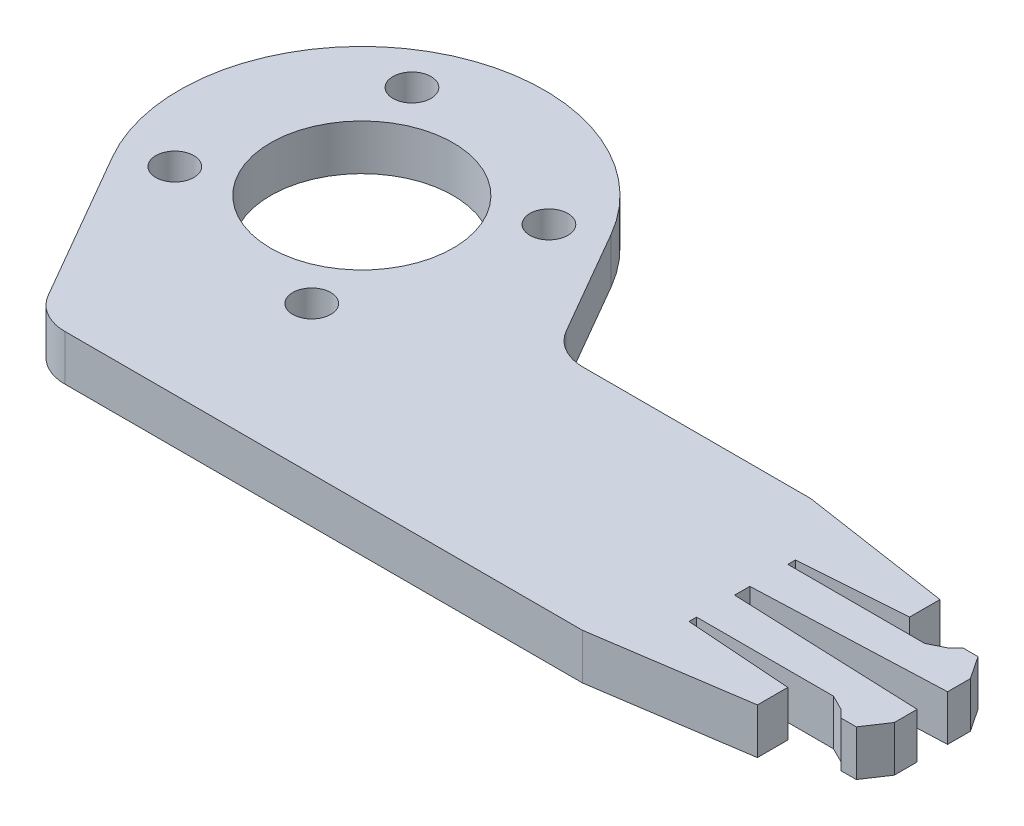
from build123d import *

# Parameters (mm, degrees)
SKETCH1_R           = 1.25
SKETCH1_R_2         = 6
BOSS_EXTRUDE1_DEPTH = 1.5
FILLET1_R           = 3


with BuildPart() as part:
    # Sketch1 → Boss-Extrude1 (new body, symmetric)
    with BuildSketch(Plane(origin=(0, 0, 0), x_dir=(1, 0, 0), z_dir=(0, 1, 0))):
        with BuildLine():
            Line((42, -16), (32, -17.5))
            Line((32, -17.5), (-3.75277675, -17.5))
            Line((-3.75277675, -17.5), (-10.392304845, -6))
            ThreePointArc((-10.392304845, -6), (-6, 10.392304845), (10.392304845, 6))
            Line((10.392304845, 6), (15.299782134, -2.5))
            Line((15.299782134, -2.5), (32, -2.5))
            Line((32, -2.5), (42, -4))
            Line((42, -4), (42, -6))
            Line((42, -6), (35, -6.5))
            Line((35, -6.5), (35, -7))
            Line((35, -7), (44, -7))
            Line((44, -7), (45, -6.5))
            Line((45, -6.5), (45.5, -6))
            Line((45.5, -6), (46.5, -6))
            Line((46.5, -6), (47.5, -7.5))
            Line((47.5, -7.5), (47.5, -9))
            Line((47.5, -9), (35, -9.5))
            Line((35, -9.5), (35, -10.5))
            Line((35, -10.5), (47.5, -11))
            Line((47.5, -11), (47.5, -12.5))
            Line((47.5, -12.5), (46.5, -14))
            Line((46.5, -14), (45.5, -14))
            Line((45.5, -14), (45, -13.5))
            Line((45, -13.5), (44, -13))
            Line((44, -13), (35, -13))
            Line((35, -13), (35, -13.5))
            Line((35, -13.5), (42, -14))
            Line((42, -14), (42, -16))
        make_face()
        with Locations((4.5, -7.794228634)):
            Circle(SKETCH1_R, mode=Mode.SUBTRACT)
        with Locations((-7.794228634, -4.5)):
            Circle(SKETCH1_R, mode=Mode.SUBTRACT)
        with Locations((-4.5, 7.794228634)):
            Circle(SKETCH1_R, mode=Mode.SUBTRACT)
        with Locations((7.794228634, 4.5)):
            Circle(SKETCH1_R, mode=Mode.SUBTRACT)
        Circle(SKETCH1_R_2, mode=Mode.SUBTRACT)
    extrude(amount=BOSS_EXTRUDE1_DEPTH, both=True)

    # Fillet1
    fillet1_edges = [part.edges().sort_by_distance(p)[0] for p in [
        (-3.75277675, 0, 17.5),
        (15.299782134, 0, 2.5),
    ]]
    fillet(fillet1_edges, radius=FILLET1_R)


solid = part.part
